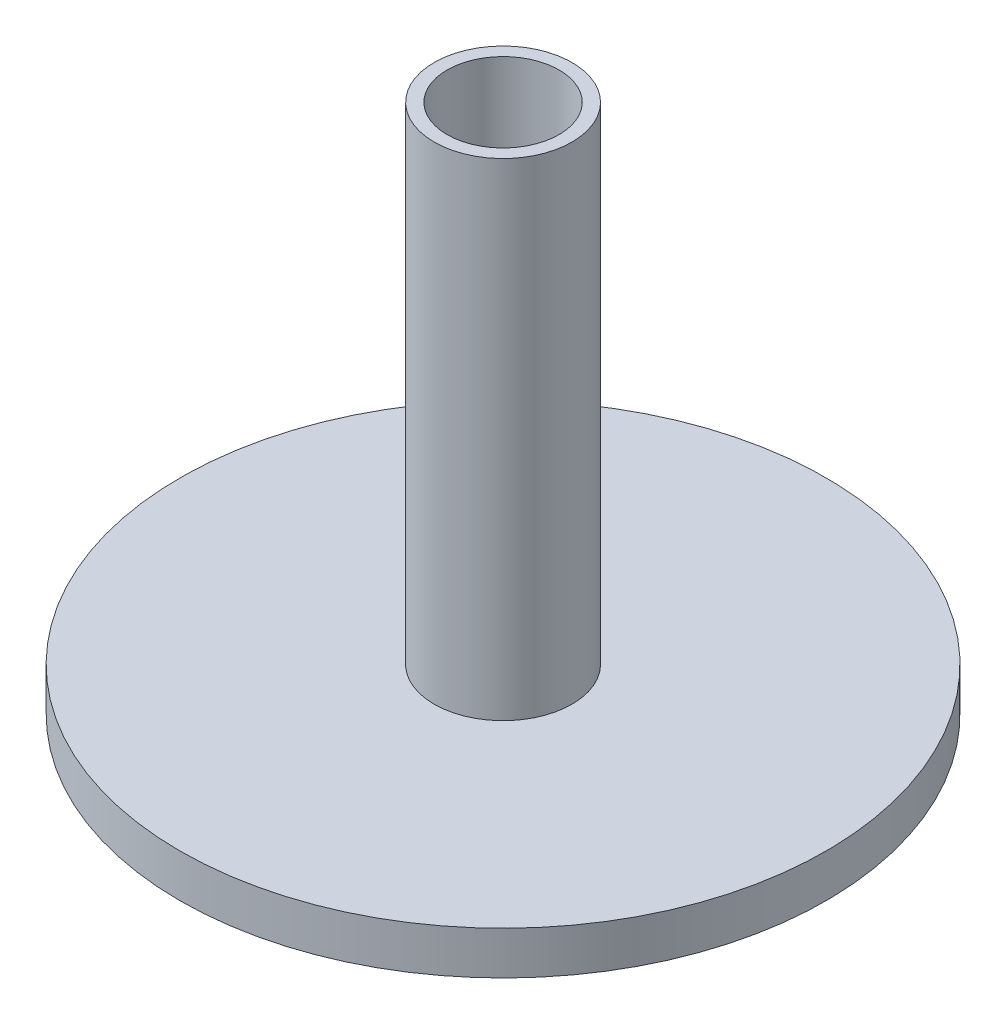
from build123d import *

# Parameters (mm, degrees)
SKETCH1_R           = 75
BOSS_EXTRUDE1_DEPTH = 10
SKETCH2_R           = 16
SKETCH2_R_2         = 13
BOSS_EXTRUDE2_DEPTH = 113


with BuildPart() as part:
    # Sketch1 → Boss-Extrude1 (new body)
    with BuildSketch(Plane(origin=(0, 0, 0), x_dir=(1, 0, 0), z_dir=(0, 1, 0))):
        Circle(SKETCH1_R)
    extrude(amount=BOSS_EXTRUDE1_DEPTH)

    # Sketch2 → Boss-Extrude2 (add)
    with BuildSketch(Plane(origin=(0, 10, 0), x_dir=(1, 0, 0), z_dir=(0, 1, 0))):
        Circle(SKETCH2_R)
        Circle(SKETCH2_R_2, mode=Mode.SUBTRACT)
    extrude(amount=BOSS_EXTRUDE2_DEPTH)


solid = part.part
